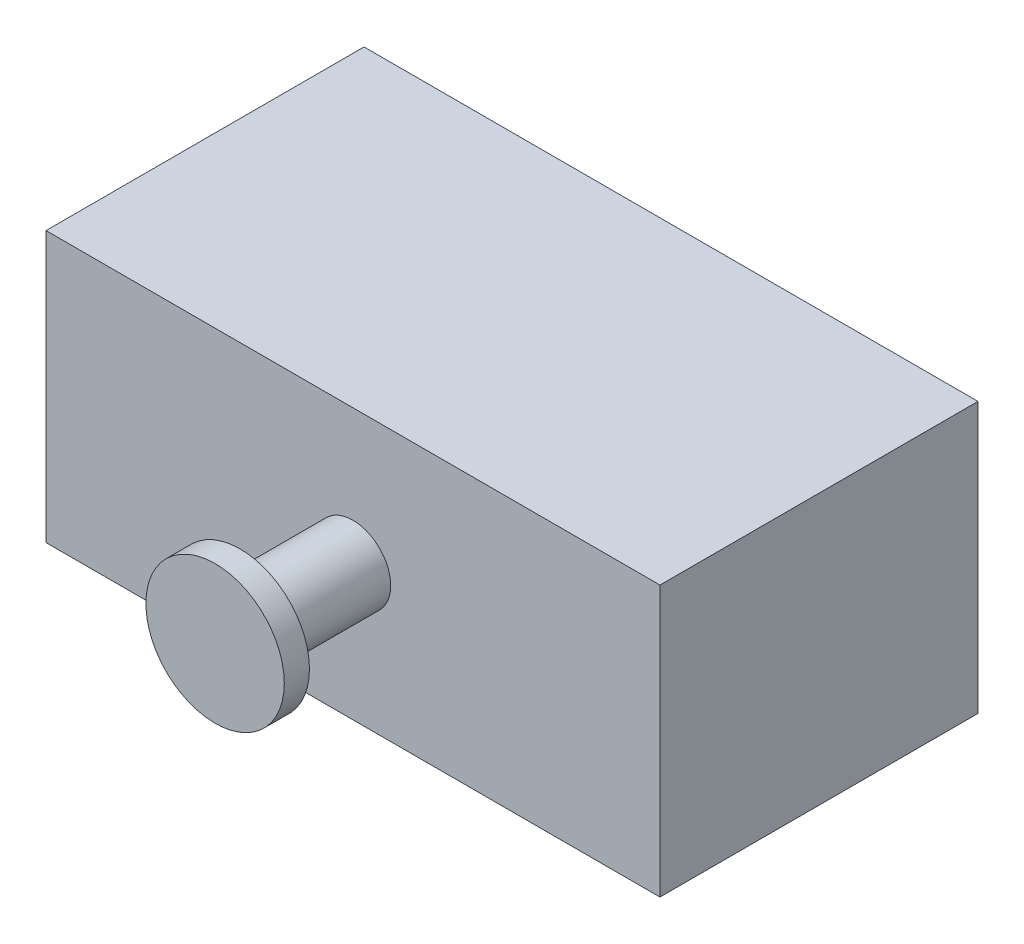
from build123d import *

# Parameters (mm, degrees)
SKETCH1_W           = 309.88
SKETCH1_H           = 136.398
BOSS_EXTRUDE1_DEPTH = 160.528
SKETCH2_R           = 19.05
BOSS_EXTRUDE2_DEPTH = 56.896
SKETCH3_R           = 34.925
BOSS_EXTRUDE3_DEPTH = 12.7


with BuildPart() as part:
    # Sketch1 → Boss-Extrude1 (new body)
    with BuildSketch(Plane.XY):
        with Locations((111.640327538, -47.419508944)):
            Rectangle(SKETCH1_W, SKETCH1_H)
    extrude(amount=BOSS_EXTRUDE1_DEPTH)

    # Sketch2 → Boss-Extrude2 (add)
    with BuildSketch(Plane.XY.offset(160.528)):
        with Locations((111.640327538, -47.419508944)):
            Circle(SKETCH2_R)
    extrude(amount=BOSS_EXTRUDE2_DEPTH)

    # Sketch3 → Boss-Extrude3 (add)
    with BuildSketch(Plane.XY.offset(217.424)):
        with Locations((111.640327538, -47.419508944)):
            Circle(SKETCH3_R)
    extrude(amount=BOSS_EXTRUDE3_DEPTH)


solid = part.part
